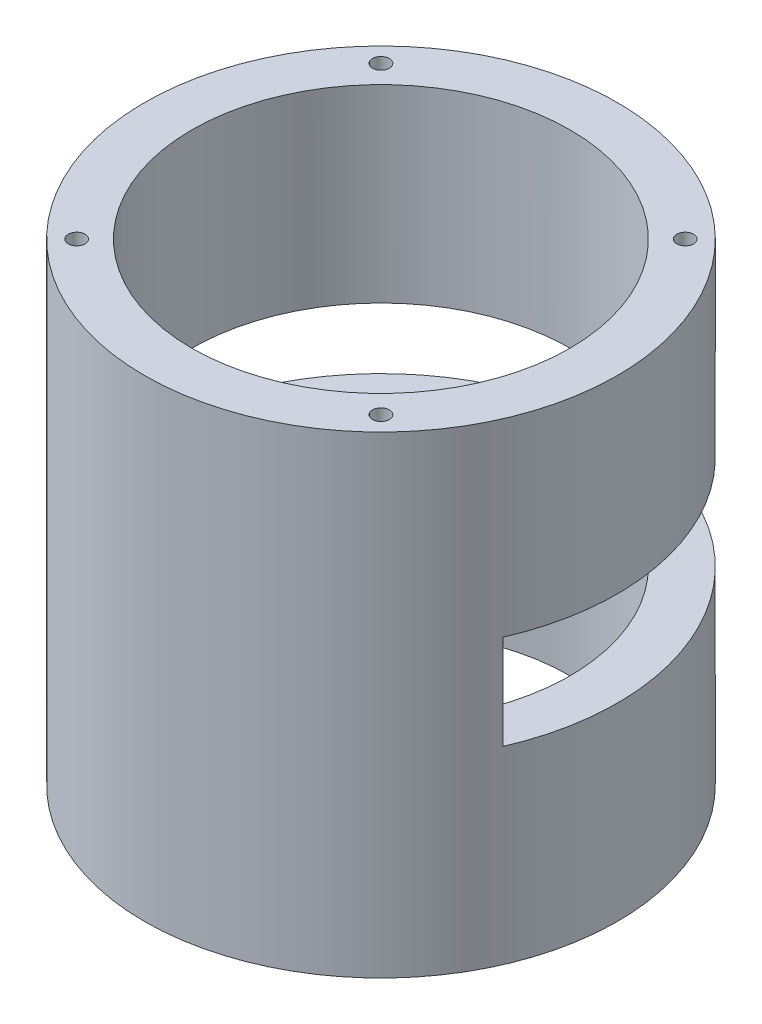
from build123d import *

# Parameters (mm, degrees)
SKETCH1_R                      = 31.75
SKETCH1_R_2                    = 25.4
BOSS_EXTRUDE1_DEPTH            = 63.5
F_4_40_TAPPED_HOLE1_AT_2_COUNT = 2
F_4_40_TAPPED_HOLE1_AT_2_PITCH = 40.860165351
F_4_40_TAPPED_HOLE1_AT_3_COUNT = 2
F_4_40_TAPPED_HOLE1_AT_3_PITCH = 57.785
F_4_40_TAPPED_HOLE1_AT_4_COUNT = 2
F_4_40_TAPPED_HOLE1_AT_4_PITCH = 40.860165351
SKETCH4_W                      = 112.670227293
SKETCH4_H                      = 56.447090519
CUT_EXTRUDE1_DEPTH             = 12.7


with BuildPart() as part:
    # Sketch1 → Boss-Extrude1 (new body)
    with BuildSketch(Plane(origin=(0, 0, 0), x_dir=(1, 0, 0), z_dir=(0, 1, 0))):
        Circle(SKETCH1_R)
        Circle(SKETCH1_R_2, mode=Mode.SUBTRACT)
    extrude(amount=BOSS_EXTRUDE1_DEPTH)

    # Sketch2 → #4-40 Tapped Hole1 (revolve, cut)
    with BuildSketch(Plane(origin=(-20.430082675, 0, 20.430082675), x_dir=(0, 0, -1), z_dir=(1, 0, 0))):
        Polygon((0, 0), (0, 8.299152758), (1.1303, 7.62), (1.1303, 0), align=None)
    f_4_40_tapped_hole1 = revolve(axis=Axis((-20.430082675, -6.35, 20.430082675), (0, 1, 0)), mode=Mode.SUBTRACT)

    # #4-40 Tapped Hole1 at 2: #4-40 Tapped Hole1 ×2
    with Locations(*[(i * F_4_40_TAPPED_HOLE1_AT_2_PITCH, 0, 0) for i in range(1, F_4_40_TAPPED_HOLE1_AT_2_COUNT)]):
        add(f_4_40_tapped_hole1, mode=Mode.SUBTRACT)

    # #4-40 Tapped Hole1 at 3: #4-40 Tapped Hole1 ×2
    with Locations(*[Vector(0.707106781, 0, -0.707106781) * (i * F_4_40_TAPPED_HOLE1_AT_3_PITCH) for i in range(1, F_4_40_TAPPED_HOLE1_AT_3_COUNT)]):
        add(f_4_40_tapped_hole1, mode=Mode.SUBTRACT)

    # #4-40 Tapped Hole1 at 4: #4-40 Tapped Hole1 ×2
    with Locations(*[(0, 0, -i * F_4_40_TAPPED_HOLE1_AT_4_PITCH) for i in range(1, F_4_40_TAPPED_HOLE1_AT_4_COUNT)]):
        add(f_4_40_tapped_hole1, mode=Mode.SUBTRACT)

    # Sketch4 → Cut-Extrude1 (cut)
    with BuildSketch(Plane(origin=(0, 25.4, 0), x_dir=(1, 0, 0), z_dir=(0, 1, 0))):
        with Locations((1.62115564, 15.52354526)):
            Rectangle(SKETCH4_W, SKETCH4_H)
    extrude(amount=CUT_EXTRUDE1_DEPTH, mode=Mode.SUBTRACT)

    # Mirror1: #4-40 Tapped Hole1 across plane
    add(f_4_40_tapped_hole1.mirror(Plane.ZX.offset(31.75)), mode=Mode.SUBTRACT)

    # Mirror1 copy 1 sketch → Mirror1 copy 1 (revolve, cut)
    with BuildSketch(Plane(origin=(20.430082675, 63.5, 20.430082675), x_dir=(0, 0, -1), z_dir=(1, 0, 0))):
        Polygon((0, 0), (0, -8.299152758), (1.1303, -7.62), (1.1303, 0), align=None)
    revolve(axis=Axis((20.430082675, 69.85, 20.430082675), (0, 1, 0)), mode=Mode.SUBTRACT)

    # Mirror1 copy 2 sketch → Mirror1 copy 2 (revolve, cut)
    with BuildSketch(Plane(origin=(20.430082675, 63.5, -20.430082675), x_dir=(0, 0, -1), z_dir=(1, 0, 0))):
        Polygon((0, 0), (0, -8.299152758), (1.1303, -7.62), (1.1303, 0), align=None)
    revolve(axis=Axis((20.430082675, 69.85, -20.430082675), (0, 1, 0)), mode=Mode.SUBTRACT)

    # Mirror1 copy 3 sketch → Mirror1 copy 3 (revolve, cut)
    with BuildSketch(Plane(origin=(-20.430082675, 63.5, -20.430082675), x_dir=(0, 0, -1), z_dir=(1, 0, 0))):
        Polygon((0, 0), (0, -8.299152758), (1.1303, -7.62), (1.1303, 0), align=None)
    revolve(axis=Axis((-20.430082675, 69.85, -20.430082675), (0, 1, 0)), mode=Mode.SUBTRACT)


solid = part.part
